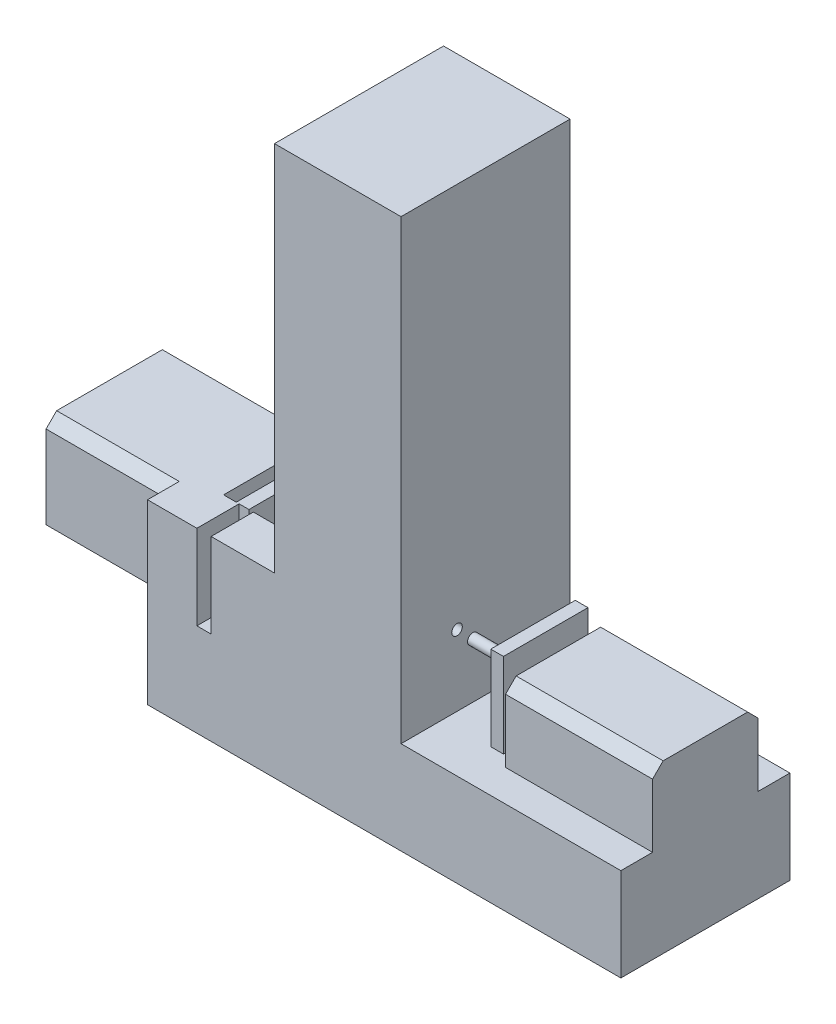
from build123d import *

# Parameters (mm, degrees)
SKETCH1_W            = 284.48
SKETCH1_H            = 101.6
BOSS_EXTRUDE1_DEPTH  = 55.88
SKETCH2_W            = 76.042421072
SKETCH2_H            = 101.6
BOSS_EXTRUDE2_DEPTH  = 274.32
SKETCH3_W            = 68.280460578
SKETCH3_H            = 6.35
CUT_EXTRUDE1_DEPTH   = 147.32
SKETCH4_R            = 3.175
CUT_EXTRUDE2_DEPTH   = 274.32
SKETCH5_W            = 25.4
SKETCH5_H            = 50.8
BOSS_EXTRUDE4_DEPTH  = 38.1
SKETCH6_W            = 29.665893143
SKETCH6_H            = 25.4
BOSS_EXTRUDE5_DEPTH  = 50.8
SKETCH7_W            = 76.2
SKETCH7_H            = 62.556650574
BOSS_EXTRUDE6_DEPTH  = 93.98
SKETCH8_R            = 6.35
BOSS_EXTRUDE7_DEPTH  = 7.62
SKETCH9_W            = 50.8
SKETCH9_H            = 50.8
BOSS_EXTRUDE8_DEPTH  = 7.62
SKETCH11_W           = 88.356231919
SKETCH11_H           = 63.5
BOSS_EXTRUDE9_DEPTH  = 44.45
SKETCH13_R           = 6.35
BOSS_EXTRUDE10_DEPTH = 7.62
SKETCH14_W           = 50.8
SKETCH14_H           = 50.8
BOSS_EXTRUDE11_DEPTH = 7.62
SKETCH15_R           = 3.175
BOSS_EXTRUDE12_DEPTH = 19.05
CHAMFER2_SIZE        = 6.35


with BuildPart() as part:
    # Sketch1 → Boss-Extrude1 (new body)
    with BuildSketch(Plane(origin=(0, 0, 0), x_dir=(1, 0, 0), z_dir=(0, 1, 0))):
        with Locations((142.24, 50.8)):
            Rectangle(SKETCH1_W, SKETCH1_H)
    extrude(amount=BOSS_EXTRUDE1_DEPTH)

    # Sketch2 → Boss-Extrude2 (add)
    with BuildSketch(Plane(origin=(0, 55.88, 0), x_dir=(1, 0, 0), z_dir=(0, 1, 0))):
        with Locations((114.337337429, 50.8)):
            Rectangle(SKETCH2_W, SKETCH2_H)
    extrude(amount=BOSS_EXTRUDE2_DEPTH)

    # Sketch3 → Cut-Extrude1 (cut)
    with BuildSketch(Plane(origin=(0, 203.2, 0), x_dir=(1, 0, 0), z_dir=(0, 1, 0))):
        with Locations((92.975896604, 33.655)):
            Rectangle(SKETCH3_W, SKETCH3_H)
        with Locations((92.975896604, 67.945)):
            Rectangle(SKETCH3_W, SKETCH3_H)
    extrude(amount=-CUT_EXTRUDE1_DEPTH, mode=Mode.SUBTRACT)

    # Sketch4 → Cut-Extrude2 (cut)
    with BuildSketch(Plane.ZY.offset(-127.116126893)):
        with Locations((-33.655, 98.425)):
            Circle(SKETCH4_R)
        with Locations((-67.945, 64.135)):
            Circle(SKETCH4_R)
    extrude(amount=-CUT_EXTRUDE2_DEPTH, mode=Mode.SUBTRACT)

    # Sketch5 → Boss-Extrude4 (add)
    with BuildSketch(Plane.ZY.offset(-76.316126893)):
        with Locations((-88.9, 81.28)):
            Rectangle(SKETCH5_W, SKETCH5_H)
        with Locations((-12.7, 81.28)):
            Rectangle(SKETCH5_W, SKETCH5_H)
    extrude(amount=BOSS_EXTRUDE4_DEPTH)

    # Sketch6 → Boss-Extrude5 (add)
    with BuildSketch(Plane(origin=(0, 55.88, 0), x_dir=(1, 0, 0), z_dir=(0, 1, 0))):
        with Locations((14.832946572, 88.9)):
            Rectangle(SKETCH6_W, SKETCH6_H)
        with Locations((14.832946572, 12.7)):
            Rectangle(SKETCH6_W, SKETCH6_H)
    extrude(amount=BOSS_EXTRUDE5_DEPTH)

    # Sketch7 → Boss-Extrude6 (add)
    with BuildSketch(Plane.ZY.offset(-20.32)):
        with Locations((-50.8, 75.401674713)):
            Rectangle(SKETCH7_W, SKETCH7_H)
    extrude(amount=BOSS_EXTRUDE6_DEPTH)

    # Sketch8 → Boss-Extrude7 (add)
    with BuildSketch(Plane(origin=(20.32, 0, 0), x_dir=(0, 0, -1), z_dir=(1, 0, 0))):
        with Locations((50.8, 81.28)):
            Circle(SKETCH8_R)
    extrude(amount=BOSS_EXTRUDE7_DEPTH)

    # Sketch9 → Boss-Extrude8 (add)
    with BuildSketch(Plane(origin=(27.94, 0, 0), x_dir=(0, 0, -1), z_dir=(1, 0, 0))):
        with Locations((50.8, 81.28)):
            Rectangle(SKETCH9_W, SKETCH9_H)
    extrude(amount=BOSS_EXTRUDE8_DEPTH)

    # Sketch11 → Boss-Extrude9 (add)
    with BuildSketch(Plane(origin=(0, 55.88, 0), x_dir=(1, 0, 0), z_dir=(0, 1, 0))):
        with Locations((240.30188404, 50.8)):
            Rectangle(SKETCH11_W, SKETCH11_H)
    extrude(amount=BOSS_EXTRUDE9_DEPTH)

    # Sketch13 → Boss-Extrude10 (add)
    with BuildSketch(Plane.ZY.offset(-196.123768081)):
        with Locations((-50.8, 78.105)):
            Circle(SKETCH13_R)
    extrude(amount=BOSS_EXTRUDE10_DEPTH)

    # Sketch14 → Boss-Extrude11 (add)
    with BuildSketch(Plane.ZY.offset(-188.503768081)):
        with Locations((-50.8, 81.28)):
            Rectangle(SKETCH14_W, SKETCH14_H)
    extrude(amount=BOSS_EXTRUDE11_DEPTH)

    # Sketch15 → Boss-Extrude12 (add)
    with BuildSketch(Plane.ZY.offset(-180.883768081)):
        with Locations((-33.655, 98.425)):
            Circle(SKETCH15_R)
        with Locations((-67.945, 64.135)):
            Circle(SKETCH15_R)
    extrude(amount=BOSS_EXTRUDE12_DEPTH)

    # Chamfer2
    chamfer2_edges = [part.edges().sort_by_distance(p)[0] for p in [
        (-36.83, 44.123349426, -88.9),
        (-36.83, 106.68, -88.9),
        (-36.83, 106.68, -12.7),
        (-36.83, 44.123349426, -12.7),
        (240.301884041, 100.33, -82.55),
        (240.301884041, 100.33, -19.05),
    ]]
    chamfer(chamfer2_edges, length=CHAMFER2_SIZE)


solid = part.part
